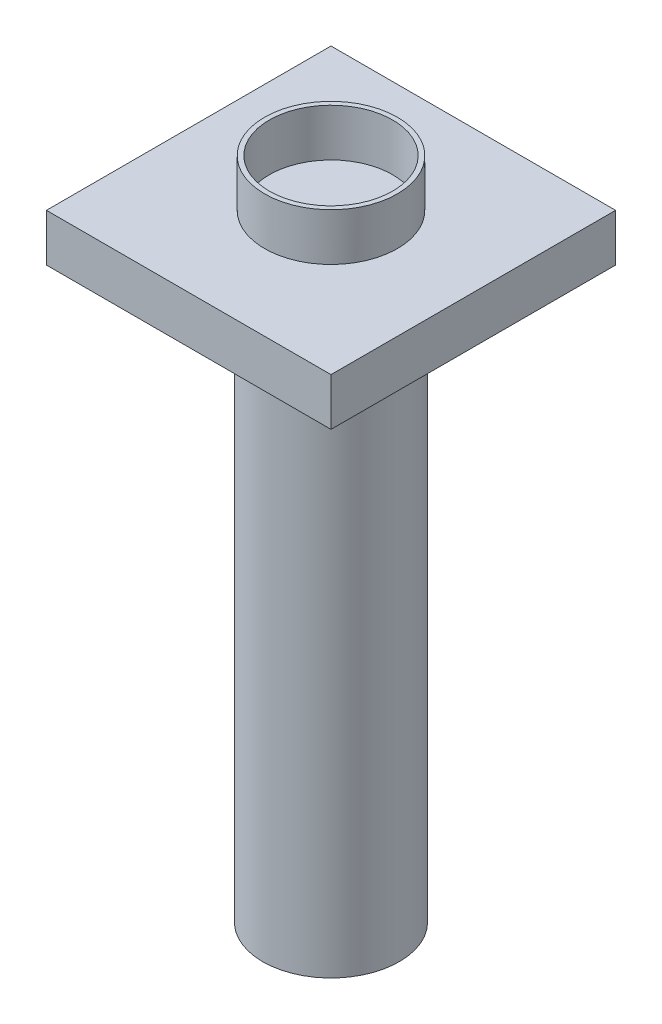
from build123d import *

# Parameters (mm, degrees)
SKETCH1_R           = 72
BOSS_EXTRUDE1_DEPTH = 600
SKETCH2_W           = 300
SKETCH2_H           = 300
BOSS_EXTRUDE2_DEPTH = 50
SKETCH3_R           = 70
SKETCH3_R_2         = 65
BOSS_EXTRUDE3_DEPTH = 50


with BuildPart() as part:
    # Sketch1 → Boss-Extrude1 (new body)
    with BuildSketch(Plane(origin=(0, 0, 0), x_dir=(1, 0, 0), z_dir=(0, 1, 0))):
        Circle(SKETCH1_R)
    extrude(amount=BOSS_EXTRUDE1_DEPTH)

    # Sketch2 → Boss-Extrude2 (add)
    with BuildSketch(Plane(origin=(0, 600, 0), x_dir=(1, 0, 0), z_dir=(0, 1, 0))):
        Rectangle(SKETCH2_W, SKETCH2_H)
    extrude(amount=BOSS_EXTRUDE2_DEPTH)

    # Sketch3 → Boss-Extrude3 (add)
    with BuildSketch(Plane(origin=(0, 650, 0), x_dir=(1, 0, 0), z_dir=(0, 1, 0))):
        Circle(SKETCH3_R)
        Circle(SKETCH3_R_2, mode=Mode.SUBTRACT)
    extrude(amount=BOSS_EXTRUDE3_DEPTH)


solid = part.part
